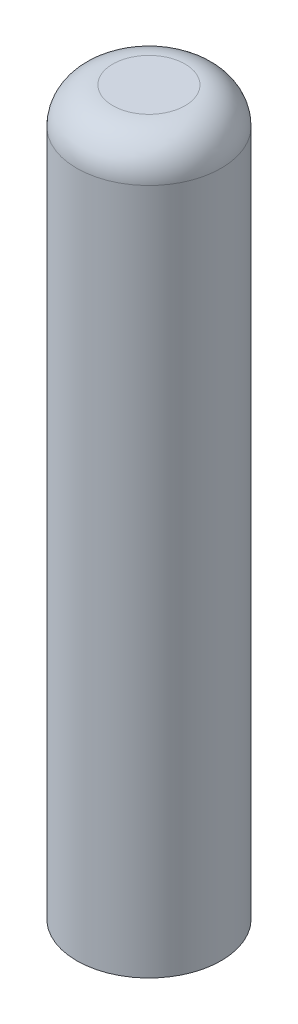
from build123d import *

# Parameters (mm, degrees)
SKETCH3_R           = 5.08
BOSS_EXTRUDE1_DEPTH = 50.8
FILLET2_R           = 2.54


with BuildPart() as part:
    # Sketch3 → Boss-Extrude1 (new body)
    with BuildSketch(Plane(origin=(0, 0, 0), x_dir=(1, 0, 0), z_dir=(0, 1, 0))):
        Circle(SKETCH3_R)
    extrude(amount=BOSS_EXTRUDE1_DEPTH)

    # Fillet2
    fillet2_edges = [part.edges().sort_by_distance(p)[0] for p in [
        (-5.08, 50.8, 0),
    ]]
    fillet(fillet2_edges, radius=FILLET2_R)


solid = part.part
